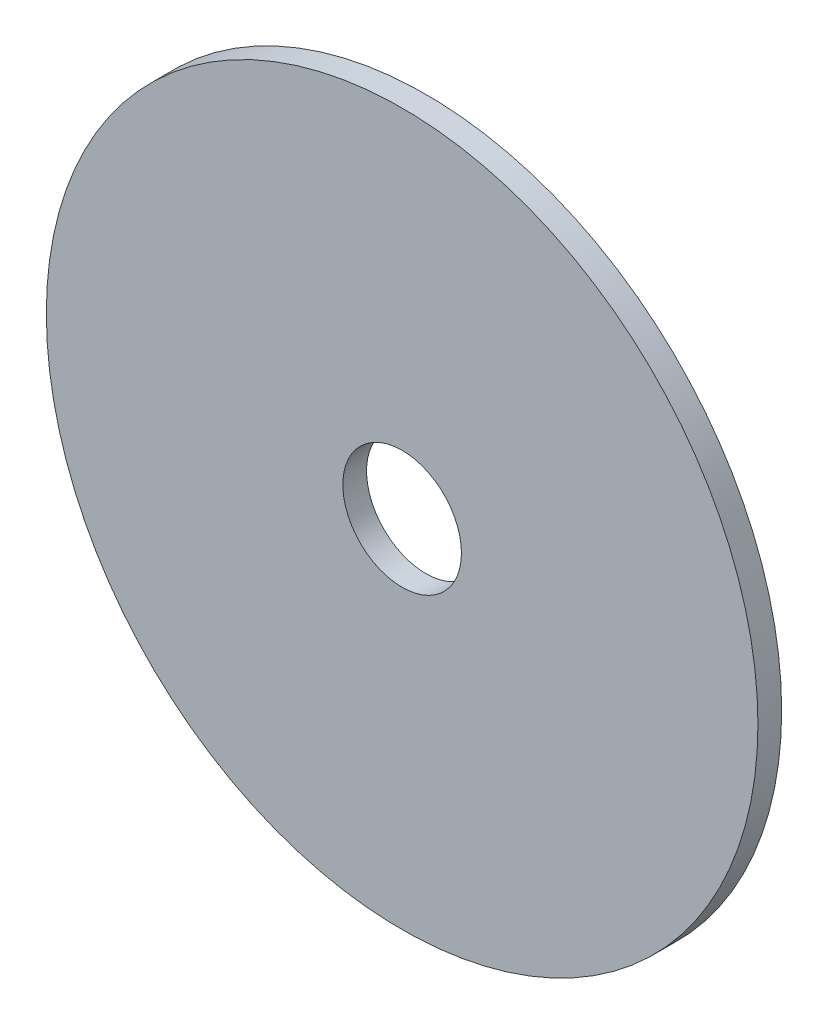
from build123d import *

# Parameters (mm, degrees)
SKETCH1_R           = 30
BOSS_EXTRUDE1_DEPTH = 2
SKETCH2_R           = 5
CUT_EXTRUDE1_DEPTH  = 4


with BuildPart() as part:
    # Sketch1 → Boss-Extrude1 (new body)
    with BuildSketch(Plane.XY):
        Circle(SKETCH1_R)
    extrude(amount=BOSS_EXTRUDE1_DEPTH)

    # Sketch2 → Cut-Extrude1 (cut)
    with BuildSketch(Plane.XY.offset(2)):
        Circle(SKETCH2_R)
    extrude(amount=-CUT_EXTRUDE1_DEPTH, mode=Mode.SUBTRACT)


solid = part.part
